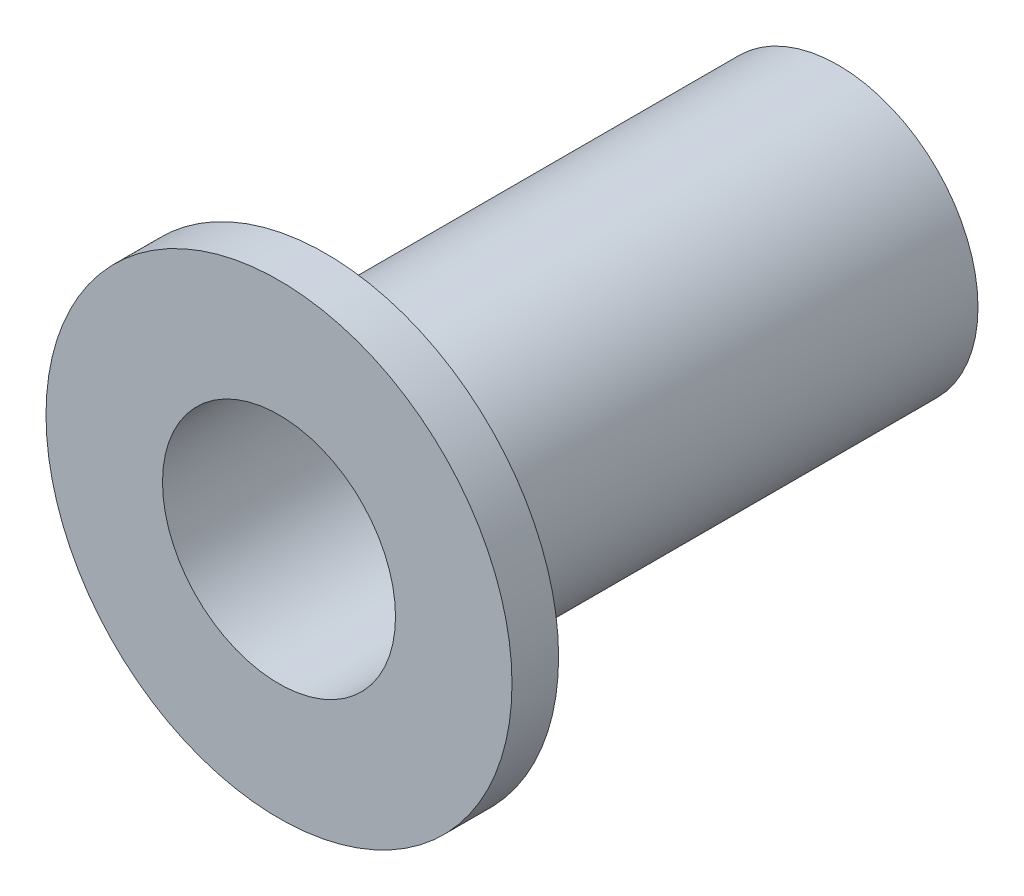
from build123d import *

# Parameters (mm, degrees)
SKETCH1_R           = 1.5
SKETCH1_R_2         = 1.25
BOSS_EXTRUDE1_DEPTH = 6
SKETCH2_R           = 2.5
SKETCH2_R_2         = 1.25
BOSS_EXTRUDE2_DEPTH = 0.5


with BuildPart() as part:
    # Sketch1 → Boss-Extrude1 (new body)
    with BuildSketch(Plane.XY):
        Circle(SKETCH1_R)
        Circle(SKETCH1_R_2, mode=Mode.SUBTRACT)
    extrude(amount=BOSS_EXTRUDE1_DEPTH)

    # Sketch2 → Boss-Extrude2 (add)
    with BuildSketch(Plane.XY.offset(6)):
        Circle(SKETCH2_R)
        Circle(SKETCH2_R_2, mode=Mode.SUBTRACT)
    extrude(amount=-BOSS_EXTRUDE2_DEPTH)


solid = part.part
